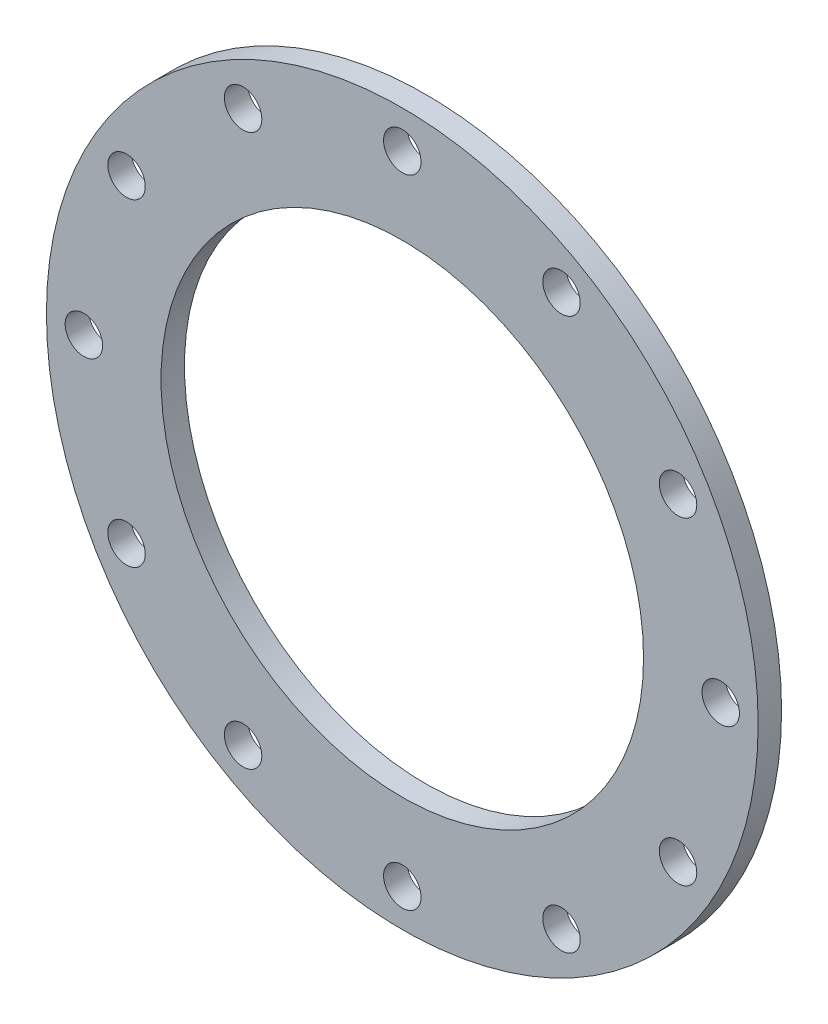
from build123d import *

# Parameters (mm, degrees)
PROFILE_SKETCH_R       = 241.3
PROFILE_SKETCH_R_2     = 163.576
BOSS_EXTRUDE1_DEPTH    = 7.9375
F_1_1_DIAMETER_HOLE1_D = 25.4
CIRPATTERN1_COUNT      = 12


with BuildPart() as part:
    # Profile Sketch → Boss-Extrude1 (new body, symmetric)
    with BuildSketch(Plane.XY):
        Circle(PROFILE_SKETCH_R)
        Circle(PROFILE_SKETCH_R_2, mode=Mode.SUBTRACT)
    extrude(amount=BOSS_EXTRUDE1_DEPTH, both=True)

    # 1 (1) Diameter Hole1 (through all)
    with Locations(Plane(origin=(215.9, 0, 7.9375), x_dir=(1, 0, 0), z_dir=(0, 0, 1))):
        with Locations((0, 0)):
            f_1_1_diameter_hole1 = Hole(F_1_1_DIAMETER_HOLE1_D / 2)

    # CirPattern1: 1 (1) Diameter Hole1 ×12 about axis
    cirpattern1_axis = Axis((0, 0, 0), (0, 0, 1))
    for i in range(1, CIRPATTERN1_COUNT):
        add(f_1_1_diameter_hole1.rotate(cirpattern1_axis, i * 360 / CIRPATTERN1_COUNT), mode=Mode.SUBTRACT)


solid = part.part
